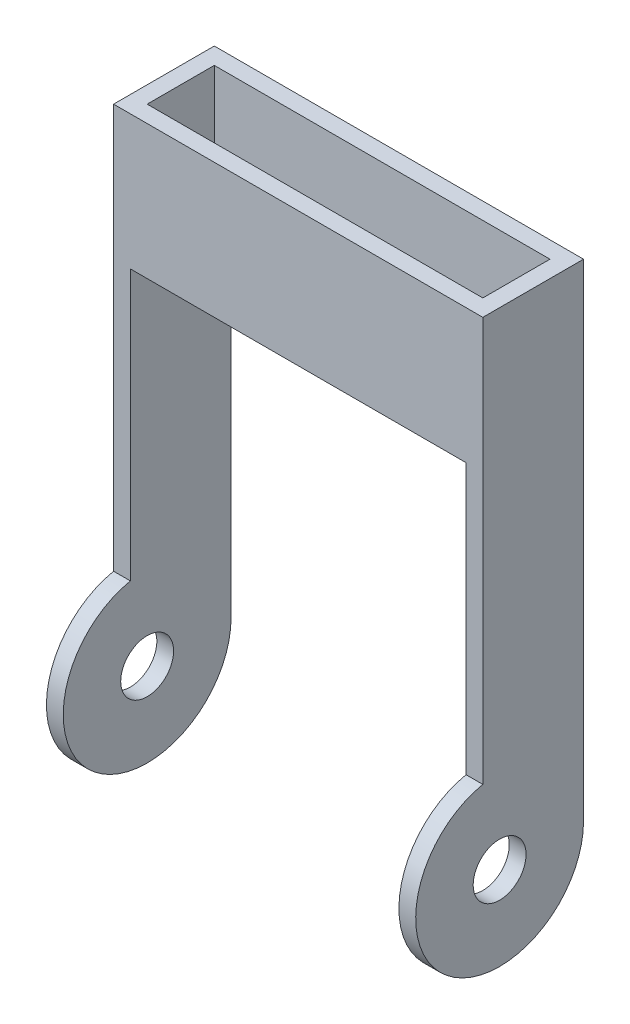
from build123d import *

# Parameters (mm, degrees)
PROBEPROFILE_W      = 69.85
PROBEPROFILE_H      = 19.05
PROBEPROFILE_W_2    = 63.5
PROBEPROFILE_H_2    = 12.7
EXTRUDE_THIN1_DEPTH = 25.4
SKETCH2_R           = 15.875
BOSS_EXTRUDE1_DEPTH = 34.925
SKETCH2_2_R         = 15.875
CUT_EXTRUDE1_DEPTH  = 31.75
SKETCH3_W           = 3.175
SKETCH3_H           = 19.05
BOSS_EXTRUDE2_DEPTH = 66.675
CUT_EXTRUDE2_START  = -69.85
SKETCH4_R           = 5.0038
CUT_EXTRUDE2_DEPTH  = 69.85


with BuildPart() as part:
    # ProbeProfile → Extrude-Thin1 (new body)
    with BuildSketch(Plane(origin=(0, 0, 0), x_dir=(1, 0, 0), z_dir=(0, 1, 0))):
        Rectangle(PROBEPROFILE_W, PROBEPROFILE_H)
        Rectangle(PROBEPROFILE_W_2, PROBEPROFILE_H_2, mode=Mode.SUBTRACT)
    extrude(amount=EXTRUDE_THIN1_DEPTH)



with BuildPart() as body_2:
    # Sketch2 → Boss-Extrude1 (new body, symmetric)
    with BuildSketch(Plane(origin=(0, 0, 0), x_dir=(0, 0, -1), z_dir=(1, 0, 0))):
        with Locations((-6.35, -66.675)):
            Circle(SKETCH2_R)
    extrude(amount=BOSS_EXTRUDE1_DEPTH, both=True)

    # Sketch2_2 → Cut-Extrude1 (cut, symmetric)
    with BuildSketch(Plane(origin=(0, 0, 0), x_dir=(0, 0, -1), z_dir=(1, 0, 0))):
        with Locations((-6.35, -66.675)):
            Circle(SKETCH2_2_R)
    extrude(amount=CUT_EXTRUDE1_DEPTH, both=True, mode=Mode.SUBTRACT)


with BuildPart() as part_1:
    add(part.part)

    add(body_2.part)  # Boss-Extrude2 merges body 2
    # Sketch3 → Boss-Extrude2 (add)
    with BuildSketch(Plane.XZ):
        with Locations((33.3375, 0)):
            Rectangle(SKETCH3_W, SKETCH3_H)
        with Locations((-33.3375, 0)):
            Rectangle(SKETCH3_W, SKETCH3_H)
    extrude(amount=BOSS_EXTRUDE2_DEPTH)

    # Sketch4 → Cut-Extrude2 (cut)
    with BuildSketch(Plane.ZY.offset(34.925).offset(CUT_EXTRUDE2_START)):
        with Locations((6.35, -66.675)):
            Circle(SKETCH4_R)
    extrude(amount=CUT_EXTRUDE2_DEPTH, mode=Mode.SUBTRACT)


solid = part_1.part
